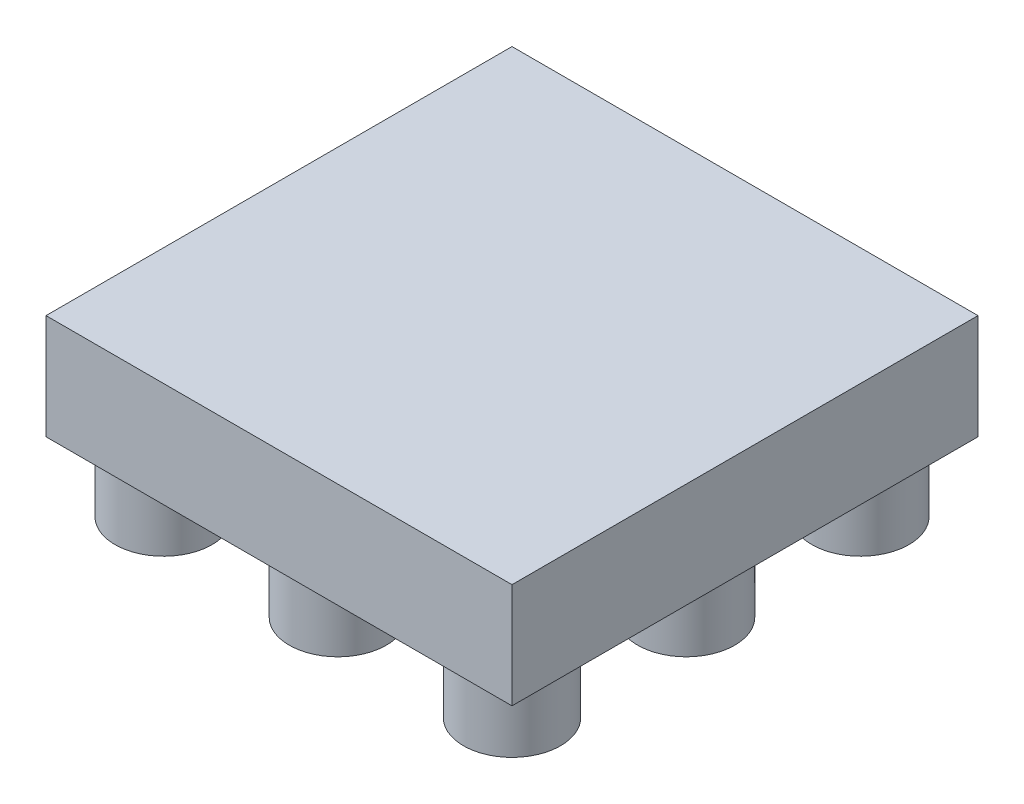
from build123d import *

# Parameters (mm, degrees)
SKETCH3_W           = 10.7
SKETCH3_H           = 10.7
BOSS_EXTRUDE2_DEPTH = 2.41
SKETCH5_R           = 1.115
BOSS_EXTRUDE3_DEPTH = 1.5875


with BuildPart() as part:
    # Sketch3 → Boss-Extrude2 (new body)
    with BuildSketch(Plane(origin=(0, 1.5875, 0), x_dir=(-1, 0, 0), z_dir=(0, 1, 0))):
        with Locations((-12.36, -20.96)):
            Rectangle(SKETCH3_W, SKETCH3_H)
    extrude(amount=BOSS_EXTRUDE2_DEPTH)

    # Sketch5 → Boss-Extrude3 (add)
    with BuildSketch(Plane.XZ.offset(-1.5875)):
        with Locations((16.36, -24.96)):
            Circle(SKETCH5_R)
        with Locations((12.36, -24.96)):
            Circle(SKETCH5_R)
        with Locations((8.36, -24.96)):
            Circle(SKETCH5_R)
        with Locations((16.36, -20.96)):
            Circle(SKETCH5_R)
        with Locations((12.36, -20.96)):
            Circle(SKETCH5_R)
        with Locations((8.36, -20.96)):
            Circle(SKETCH5_R)
        with Locations((16.36, -16.96)):
            Circle(SKETCH5_R)
        with Locations((12.36, -16.96)):
            Circle(SKETCH5_R)
        with Locations((8.36, -16.96)):
            Circle(SKETCH5_R)
    extrude(amount=BOSS_EXTRUDE3_DEPTH)


solid = part.part
